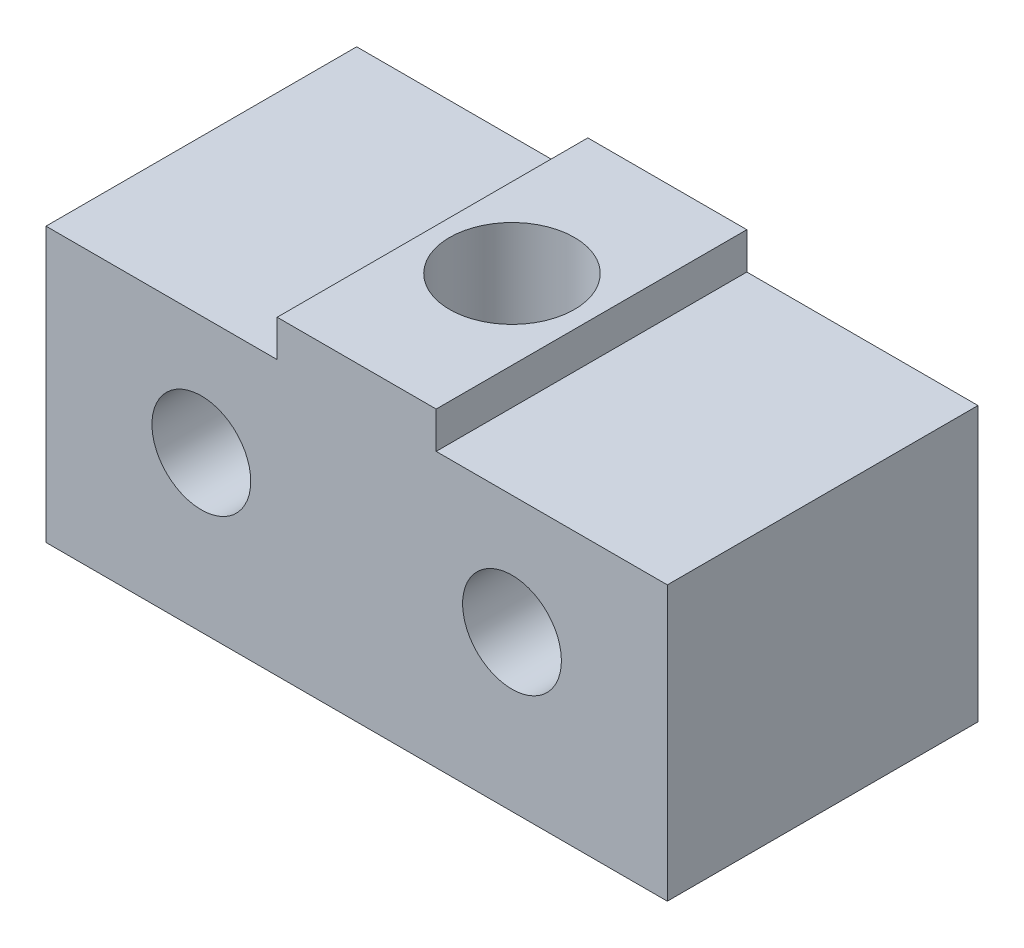
from build123d import *

# Parameters (mm, degrees)
SKETCH5_W                                       = 25.4
SKETCH5_H                                       = 12.7
BOSS_EXTRUDE2_DEPTH                             = 12.7
F_10_32_TAPPED_HOLE1_D                          = 4.0386
SKETCH6_W                                       = 9.45
SKETCH6_H                                       = 1.5
CUT_EXTRUDE1_DEPTH                              = 12.7
CBORE_FOR_10_SOCKET_HEAD_CAP_SCREW2_D           = 5.1054
CBORE_FOR_10_SOCKET_HEAD_CAP_SCREW2_CBORE_D     = 9.525
CBORE_FOR_10_SOCKET_HEAD_CAP_SCREW2_CBORE_DEPTH = 4.826


with BuildPart() as part:
    # Sketch5 → Boss-Extrude2 (new body)
    with BuildSketch(Plane.XY):
        with Locations((-12.7, -6.35)):
            Rectangle(SKETCH5_W, SKETCH5_H)
    extrude(amount=BOSS_EXTRUDE2_DEPTH)

    # #10-32 Tapped Hole1 (through all)
    with Locations(Plane.XY.offset(12.7)):
        with Locations((-19.05, -6.35)):
            f_10_32_tapped_hole1 = Hole(F_10_32_TAPPED_HOLE1_D / 2)

    # Mirror1: #10-32 Tapped Hole1 across plane
    add(f_10_32_tapped_hole1.mirror(Plane.ZY.offset(12.7)), mode=Mode.SUBTRACT)

    # Sketch6 → Cut-Extrude1 (cut)
    with BuildSketch(Plane.XY.offset(12.7)):
        with Locations((-20.675, -0.75)):
            Rectangle(SKETCH6_W, SKETCH6_H)
        with Locations((-4.725, -0.75)):
            Rectangle(SKETCH6_W, SKETCH6_H)
    extrude(amount=-CUT_EXTRUDE1_DEPTH, mode=Mode.SUBTRACT)

    # CBORE for #10 Socket Head Cap Screw2 (through all)
    with Locations(Plane(origin=(0, -12.7, 0), x_dir=(-1, 0, 0), z_dir=(0, -1, 0))):
        with Locations((12.7, -6.35)):
            CounterBoreHole(CBORE_FOR_10_SOCKET_HEAD_CAP_SCREW2_D / 2, CBORE_FOR_10_SOCKET_HEAD_CAP_SCREW2_CBORE_D / 2, CBORE_FOR_10_SOCKET_HEAD_CAP_SCREW2_CBORE_DEPTH)


solid = part.part
